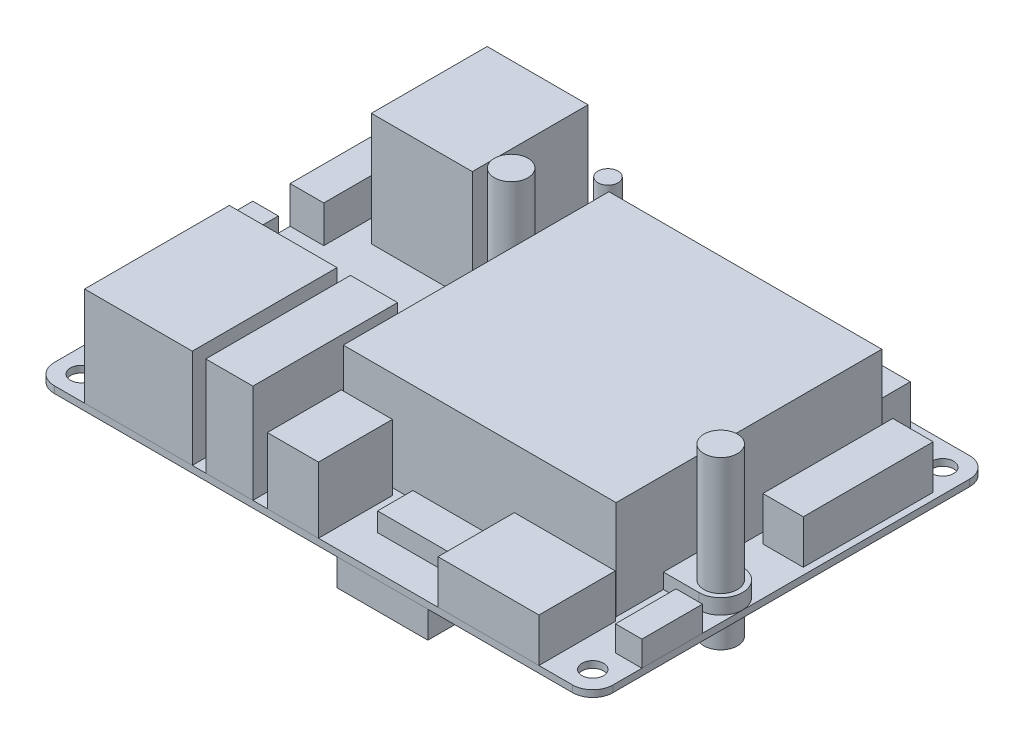
from build123d import *

# Parameters (mm, degrees)
PCB_EXTRUDE_DEPTH            = 1
SKETCH3_R                    = 1.6
PCB_HOLES_AND_TABS_DEPTH     = 51.926417506
UART_EXTRUDE_DEPTH           = 5.5
SKETCH4_3_W                  = 3.8
SKETCH4_3_H                  = 7.3
BATTERY_AND_FAN_HEADER_DEPTH = 6
HEATSINK_FAN_DEPTH           = 14.7
SKETCH4_6_W                  = 6
SKETCH4_6_H                  = 6
POWERBUTTON_DEPTH            = 3.5
SKETCH5_R                    = 1.5
POWERBUTTONSWITCH_DEPTH      = 8.5
SKETCH4_8_W                  = 7.6
SKETCH4_8_H                  = 10.983605977
DCPOWERJACK_DEPTH            = 9.8
HEATSINKMOUNTTABS_START      = 2.25
SKETCH4_11_R                 = 1.6
HEATSINKMOUNTTABS_DEPTH      = 2.25
SKETCH6_R                    = 2.5
HEATSINKSPRINGS_DEPTH        = 17.5
SKETCH4_13_W                 = 11.4
SKETCH4_13_H                 = 5.25
MICROSD_DEPTH                = 2.8
UNDERSIDE_START              = 4
SKETCH7_R                    = 2.5
SKETCH7_W                    = 13.5
SKETCH7_H                    = 18.5
UNDERSIDE_DEPTH              = 4
GROSS_COMPONENTS_15_W        = 16
GROSS_COMPONENTS_15_H        = 21.5
ETHERNET_DEPTH               = 14.7
GROSS_COMPONENTS_16_W        = 15
GROSS_COMPONENTS_16_H        = 17.193227116
USBX2_DEPTH                  = 16.8
GROSS_COMPONENTS_17_W        = 7
GROSS_COMPONENTS_17_H        = 21.5
USBVERTICAL_DEPTH            = 14.7
GROSS_COMPONENTS_18_W        = 15
GROSS_COMPONENTS_18_H        = 11.350223911
HDMI_DEPTH                   = 6.5
GROSS_COMPONENTS_19_W        = 3.930498855
GROSS_COMPONENTS_19_H        = 9
DIP_DEPTH                    = 3.75
GROSS_COMPONENTS_21_W        = 37.3
GROSS_COMPONENTS_21_H        = 6
GROSS_COMPONENTS_21_W_2      = 6
GROSS_COMPONENTS_21_H_2      = 19.3
PINHEADERS_DEPTH             = 6.5


with BuildPart() as part:
    # Sketch1 → PCB Extrude (new body)
    with BuildSketch(Plane(origin=(0, 0, 0), x_dir=(1, 0, 0), z_dir=(0, 1, 0))):
        with BuildLine():
            Line((-38.5, -29.5), (38.5, -29.5))
            ThreePointArc((38.5, -29.5), (40.621320344, -28.621320344), (41.5, -26.5))
            Line((41.5, -26.5), (41.5, 26.5))
            ThreePointArc((41.5, 26.5), (40.621320344, 28.621320344), (38.5, 29.5))
            Line((38.5, 29.5), (-38.5, 29.5))
            ThreePointArc((-38.5, 29.5), (-40.621320344, 28.621320344), (-41.5, 26.5))
            Line((-41.5, 26.5), (-41.5, -26.5))
            ThreePointArc((-41.5, -26.5), (-40.621320344, -28.621320344), (-38.5, -29.5))
        make_face()
    extrude(amount=-PCB_EXTRUDE_DEPTH)

    # Sketch3 → PCB Holes and Tabs (cut, through all)
    with BuildSketch(Plane(origin=(0, 0, 0), x_dir=(1, 0, 0), z_dir=(0, 1, 0))):
        with Locations((-12.830824848, 12.70463972)):
            Circle(SKETCH3_R)
        with Locations((38.231306466, -7.222675777)):
            Circle(SKETCH3_R)
        with Locations((-38, 26)):
            Circle(SKETCH3_R)
        with Locations((38, 26)):
            Circle(SKETCH3_R)
        with Locations((38, -26)):
            Circle(SKETCH3_R)
        with Locations((-38, -26)):
            Circle(SKETCH3_R)
    extrude(amount=-PCB_HOLES_AND_TABS_DEPTH, mode=Mode.SUBTRACT)

    # Gross Components → UART Extrude (add)
    with BuildSketch(Plane(origin=(-30.681810048, 0, -29.297110237), x_dir=(1, 0, 0), z_dir=(0, 1, 0))):
        Polygon((-7.232403514, -8.562818523), (-10.818189952, -8.562818523), (-10.818189952, -20.762818523), (-5.818189952, -20.762818523), (-5.818189952, -9.977032085), align=None)
    extrude(amount=UART_EXTRUDE_DEPTH)

    # Sketch4_3 → Battery and Fan Header (add)
    with BuildSketch(Plane(origin=(-30.681810048, 0, -29.297110237), x_dir=(1, 0, 0), z_dir=(0, 1, 0))):
        with Locations((-8.918189952, -29.954934674)):
            Rectangle(SKETCH4_3_W, SKETCH4_3_H)
        with Locations((17.820043283, -33.259722768)):
            Rectangle(SKETCH4_3_W, SKETCH4_3_H)
    extrude(amount=BATTERY_AND_FAN_HEADER_DEPTH)

    # Sketch4_4 → HeatSink_Fan (add)
    with BuildSketch(Plane(origin=(-30.681810048, 0, -29.297110237), x_dir=(1, 0, 0), z_dir=(0, 1, 0))):
        Polygon((63.653948261, -46.804143445), (63.653948261, -39.769786014), (63.653948261, -33.269786014), (63.653948261, -7.329049339), (23.119229334, -7.329049339), (23.119229334, -13.342470517), (23.119229334, -19.842470517), (23.119229334, -46.804143445), align=None)
    extrude(amount=HEATSINK_FAN_DEPTH)

    # Sketch4_6 → PowerButton (add)
    with BuildSketch(Plane(origin=(-30.681810048, 0, -29.297110237), x_dir=(1, 0, 0), z_dir=(0, 1, 0))):
        with Locations((18.444226135, -2.797110237)):
            Rectangle(SKETCH4_6_W, SKETCH4_6_H)
    extrude(amount=POWERBUTTON_DEPTH)

    # Sketch5 → PowerButtonSwitch (add)
    with BuildSketch(Plane(origin=(0, 3.5, 0), x_dir=(1, 0, 0), z_dir=(0, 1, 0))):
        with Locations((-12.237583913, 26.5)):
            Circle(SKETCH5_R)
    extrude(amount=POWERBUTTONSWITCH_DEPTH)

    # Sketch4_8 → DCPowerJack (add)
    with BuildSketch(Plane(origin=(-30.681810048, 0, -29.297110237), x_dir=(1, 0, 0), z_dir=(0, 1, 0))):
        with Locations((27.627643628, -53.305307249)):
            Rectangle(SKETCH4_8_W, SKETCH4_8_H)
    extrude(amount=DCPOWERJACK_DEPTH)

    # Sketch4_11 → HeatSinkMountTabs (add)
    # profile 1 of 2: a face of its own
    with BuildSketch(Plane(origin=(-30.681810048, 0, -29.297110237), x_dir=(1, 0, 0), z_dir=(0, 1, 0)).offset(HEATSINKMOUNTTABS_START)):
        with BuildLine():
            Line((63.653948261, -39.769786014), (68.913116514, -39.769786014))
            ThreePointArc((68.913116514, -39.769786014), (72.163116514, -36.519786014), (68.913116514, -33.269786014))
            Line((68.913116514, -33.269786014), (63.653948261, -33.269786014))
            Line((63.653948261, -33.269786014), (63.653948261, -39.769786014))
        make_face()
        with Locations((68.913116514, -36.519786014)):
            Circle(SKETCH4_11_R, mode=Mode.SUBTRACT)
    # profile 2 of 2: a face of its own
    with BuildSketch(Plane(origin=(-30.681810048, 0, -29.297110237), x_dir=(1, 0, 0), z_dir=(0, 1, 0)).offset(HEATSINKMOUNTTABS_START)):
        with BuildLine():
            Line((17.8509852, -19.842470517), (23.119229334, -19.842470517))
            Line((23.119229334, -19.842470517), (23.119229334, -13.342470517))
            Line((23.119229334, -13.342470517), (17.8509852, -13.342470517))
            ThreePointArc((17.8509852, -13.342470517), (14.6009852, -16.592470517), (17.8509852, -19.842470517))
        make_face()
        with Locations((17.8509852, -16.592470517)):
            Circle(SKETCH4_11_R, mode=Mode.SUBTRACT)
    extrude(amount=-HEATSINKMOUNTTABS_DEPTH)

    # Sketch6 → HeatSinkSprings (add)
    with BuildSketch(Plane(origin=(0, 2.25, 0), x_dir=(1, 0, 0), z_dir=(0, 1, 0))):
        with Locations((38.231306466, -7.222675777)):
            Circle(SKETCH6_R)
        with Locations((-12.830824848, 12.70463972)):
            Circle(SKETCH6_R)
    extrude(amount=HEATSINKSPRINGS_DEPTH)

    # Sketch4_13 → microSD (add)
    with BuildSketch(Plane(origin=(-30.681810048, 0, -29.297110237), x_dir=(1, 0, 0), z_dir=(0, 1, 0))):
        with Locations((40.797038503, -51.062962156)):
            Rectangle(SKETCH4_13_W, SKETCH4_13_H)
    extrude(amount=MICROSD_DEPTH)

    # Sketch7 → UnderSide (add)
    with BuildSketch(Plane.XZ.offset(1).offset(UNDERSIDE_START)):
        with Locations((-12.830824848, -12.70463972)):
            Circle(SKETCH7_R)
        with Locations((38.231306466, 7.222675777)):
            Circle(SKETCH7_R)
        with Locations((10.25, 20.25)):
            Rectangle(SKETCH7_W, SKETCH7_H)
    extrude(amount=-UNDERSIDE_DEPTH)

    # Gross Components_15 → Ethernet (add)
    with BuildSketch(Plane(origin=(-30.681810048, 0, -29.297110237), x_dir=(1, 0, 0), z_dir=(0, 1, 0))):
        with Locations((4.681810048, -48.047110237)):
            Rectangle(GROSS_COMPONENTS_15_W, GROSS_COMPONENTS_15_H)
    extrude(amount=ETHERNET_DEPTH)

    # Gross Components_16 → USBx2 (add)
    with BuildSketch(Plane(origin=(-30.681810048, 0, -29.297110237), x_dir=(1, 0, 0), z_dir=(0, 1, 0))):
        with Locations((4.981810048, -8.393723795)):
            Rectangle(GROSS_COMPONENTS_16_W, GROSS_COMPONENTS_16_H)
    extrude(amount=USBX2_DEPTH)

    # Gross Components_17 → USBvertical (add)
    with BuildSketch(Plane(origin=(-30.681810048, 0, -29.297110237), x_dir=(1, 0, 0), z_dir=(0, 1, 0))):
        with Locations((18.181810048, -48.047110237)):
            Rectangle(GROSS_COMPONENTS_17_W, GROSS_COMPONENTS_17_H)
    extrude(amount=USBVERTICAL_DEPTH)

    # Gross Components_18 → HDMI (add)
    with BuildSketch(Plane(origin=(-30.681810048, 0, -29.297110237), x_dir=(1, 0, 0), z_dir=(0, 1, 0))):
        with Locations((56.681810048, -53.121998282)):
            Rectangle(GROSS_COMPONENTS_18_W, GROSS_COMPONENTS_18_H)
    extrude(amount=HDMI_DEPTH)

    # Gross Components_19 → DIP (add)
    with BuildSketch(Plane(origin=(-30.681810048, 0, -29.297110237), x_dir=(1, 0, 0), z_dir=(0, 1, 0))):
        with Locations((70.216560621, -46.997110237)):
            Rectangle(GROSS_COMPONENTS_19_W, GROSS_COMPONENTS_19_H)
    extrude(amount=DIP_DEPTH)

    # Gross Components_21 → PinHeaders (add)
    with BuildSketch(Plane(origin=(-30.681810048, 0, -29.297110237), x_dir=(1, 0, 0), z_dir=(0, 1, 0))):
        with Locations((43.106667362, -4.197110237)):
            Rectangle(GROSS_COMPONENTS_21_W, GROSS_COMPONENTS_21_H)
        with Locations((68.181810048, -16.871799168)):
            Rectangle(GROSS_COMPONENTS_21_W_2, GROSS_COMPONENTS_21_H_2)
    extrude(amount=PINHEADERS_DEPTH)


solid = part.part
